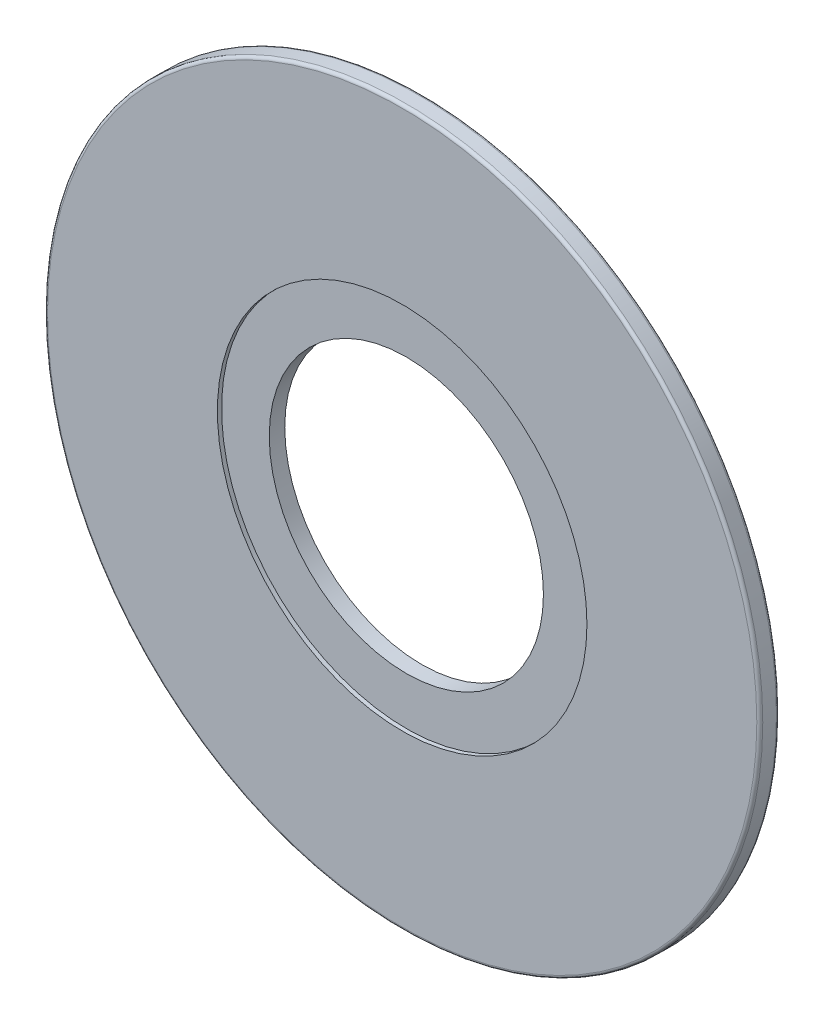
from build123d import *

# Parameters (mm, degrees)
ESBO_O1_R                  = 30
RESSALTO_EXTRUS_O1_DEPTH   = 2
ESBO_O2_R                  = 30
ESBO_O2_R_2                = 11.5
CORTE_EXTRUS_O6_DEPTH      = 0.35
ESBO_O9_R                  = 11.5
CORTE_EXTRUS_O7_DEPTH      = 37
CORTE_EXTRUS_O7_DEPTH_BACK = 12.35
FILETE2_R                  = 0.25
ESBO_O10_R                 = 15.5
CORTE_EXTRUS_O8_DEPTH      = 0.35


with BuildPart() as part:
    # Esboço1 → Ressalto-extrusão1 (new body)
    with BuildSketch(Plane.XY):
        Circle(ESBO_O1_R)
    extrude(amount=RESSALTO_EXTRUS_O1_DEPTH)

    # Esboço2 → Corte-extrusão6 (cut)
    with BuildSketch(Plane(origin=(0, 0, 0), x_dir=(-1, 0, 0), z_dir=(0, 0, -1))):
        Circle(ESBO_O2_R)
        Circle(ESBO_O2_R_2, mode=Mode.SUBTRACT)
        with BuildLine():
            Line((-17.462157831, -20.593033868), (-9.611804273, -12.159902081))
            ThreePointArc((-9.611804273, -12.159902081), (-5.674511924, -14.423935469), (-1.25, -15.449514555))
            Line((-1.25, -15.449514555), (-1.25, -26.971049294))
            ThreePointArc((-1.25, -26.971049294), (-9.884633674, -25.125565011), (-17.462157831, -20.593033868))
        make_face(mode=Mode.SUBTRACT)
        with BuildLine():
            Line((1.25, -26.971049294), (1.25, -15.449514555))
            ThreePointArc((1.25, -15.449514555), (6.35222208, -14.138573996), (10.720700103, -11.194489238))
            Line((10.720700103, -11.194489238), (19.334766503, -18.845869687))
            ThreePointArc((19.334766503, -18.845869687), (11.065161043, -24.628483735), (1.25, -26.971049294))
        make_face(mode=Mode.SUBTRACT)
        with BuildLine():
            Line((-26.971049294, -1.25), (-15.449514555, -1.25))
            ThreePointArc((-15.449514555, -1.25), (-14.211748443, -6.186776721), (-11.441667216, -10.456493261))
            Line((-11.441667216, -10.456493261), (-19.292020774, -18.889625048))
            ThreePointArc((-19.292020774, -18.889625048), (-24.755948901, -10.7769659), (-26.971049294, -1.25))
        make_face(mode=Mode.SUBTRACT)
        with BuildLine():
            Line((-26.971049294, 1.25), (-15.449514555, 1.25))
            ThreePointArc((-15.449514555, 1.25), (-14.489180857, 5.50578224), (-12.380934748, 9.325366201))
            Line((-12.380934748, 9.325366201), (-20.995001147, 16.97674665))
            ThreePointArc((-20.995001147, 16.97674665), (-25.239218268, 9.590717451), (-26.971049294, 1.25))
        make_face(mode=Mode.SUBTRACT)
        with BuildLine():
            Line((20.995001147, -16.976746651), (12.380934747, -9.325366201))
            ThreePointArc((12.380934747, -9.325366201), (14.489180857, -5.50578224), (15.449514555, -1.25))
            Line((15.449514555, -1.25), (26.971049294, -1.25))
            ThreePointArc((26.971049294, -1.25), (25.239218268, -9.590717451), (20.995001147, -16.976746651))
        make_face(mode=Mode.SUBTRACT)
        with BuildLine():
            Line((15.449514555, 1.25), (26.971049294, 1.25))
            ThreePointArc((26.971049294, 1.25), (24.755948901, 10.776965901), (19.292020774, 18.889625048))
            Line((19.292020774, 18.889625048), (11.441667216, 10.456493261))
            ThreePointArc((11.441667216, 10.456493261), (14.211748443, 6.186776721), (15.449514555, 1.25))
        make_face(mode=Mode.SUBTRACT)
        with BuildLine():
            Line((9.611804273, 12.159902081), (17.462157831, 20.593033868))
            ThreePointArc((17.462157831, 20.593033868), (9.884633674, 25.125565011), (1.25, 26.971049294))
            Line((1.25, 26.971049294), (1.25, 15.449514555))
            ThreePointArc((1.25, 15.449514555), (5.674511924, 14.423935469), (9.611804273, 12.159902081))
        make_face(mode=Mode.SUBTRACT)
        with BuildLine():
            Line((-1.25, 15.449514555), (-1.25, 26.971049294))
            ThreePointArc((-1.25, 26.971049294), (-11.065161043, 24.628483735), (-19.334766503, 18.845869687))
            Line((-19.334766503, 18.845869687), (-10.720700104, 11.194489238))
            ThreePointArc((-10.720700104, 11.194489238), (-6.35222208, 14.138573996), (-1.25, 15.449514555))
        make_face(mode=Mode.SUBTRACT)
    extrude(amount=-CORTE_EXTRUS_O6_DEPTH, mode=Mode.SUBTRACT)

    # Esboço9 → Corte-extrusão7 (cut, two sides)
    with BuildSketch(Plane(origin=(0, 0, 0), x_dir=(-1, 0, 0), z_dir=(0, 0, -1))) as corte_extrus_o7_sk:
        Circle(ESBO_O9_R)
    extrude(amount=CORTE_EXTRUS_O7_DEPTH, mode=Mode.SUBTRACT)
    extrude(corte_extrus_o7_sk.sketch, amount=-CORTE_EXTRUS_O7_DEPTH_BACK, mode=Mode.SUBTRACT)

    # Filete2
    filete2_edges = [part.edges().sort_by_distance(p)[0] for p in [
        (-30, 0, 0.35),
        (-30, 0, 2),
    ]]
    fillet(filete2_edges, radius=FILETE2_R)

    # Esboço10 → Corte-extrusão8 (cut)
    with BuildSketch(Plane.XY.offset(2)):
        Circle(ESBO_O10_R)
    extrude(amount=-CORTE_EXTRUS_O8_DEPTH, mode=Mode.SUBTRACT)


solid = part.part
